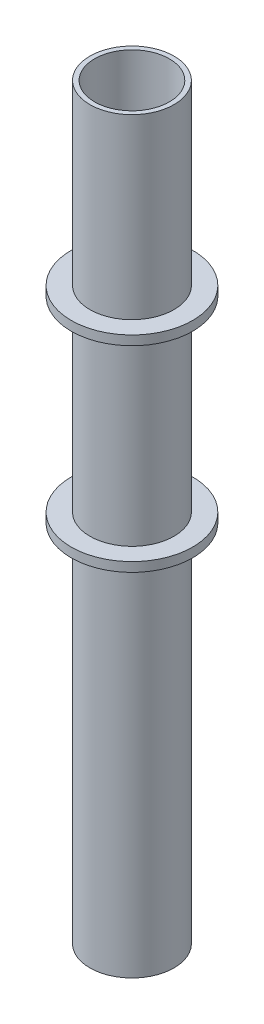
from build123d import *

# Parameters (mm, degrees)
SKETCH1_R           = 22.5
SKETCH1_R_2         = 20
BOSS_EXTRUDE1_DEPTH = 200
SKETCH2_R           = 32.5
SKETCH2_R_2         = 22.5
BOSS_EXTRUDE2_DEPTH = 5
SKETCH3_R           = 32.5
SKETCH3_R_2         = 22.5
BOSS_EXTRUDE3_DEPTH = 5


with BuildPart() as part:
    # Sketch1 → Boss-Extrude1 (new body, symmetric)
    with BuildSketch(Plane(origin=(0, 0, 0), x_dir=(1, 0, 0), z_dir=(0, 1, 0))):
        Circle(SKETCH1_R)
        Circle(SKETCH1_R_2, mode=Mode.SUBTRACT)
    extrude(amount=BOSS_EXTRUDE1_DEPTH, both=True)

    # Sketch2 → Boss-Extrude2 (add)
    with BuildSketch(Plane(origin=(0, 100, 0), x_dir=(1, 0, 0), z_dir=(0, 1, 0))):
        Circle(SKETCH2_R)
        Circle(SKETCH2_R_2, mode=Mode.SUBTRACT)
    extrude(amount=BOSS_EXTRUDE2_DEPTH)

    # Sketch3 → Boss-Extrude3 (add)
    with BuildSketch(Plane(origin=(0, 0, 0), x_dir=(1, 0, 0), z_dir=(0, 1, 0))):
        Circle(SKETCH3_R)
        Circle(SKETCH3_R_2, mode=Mode.SUBTRACT)
    extrude(amount=-BOSS_EXTRUDE3_DEPTH)


solid = part.part
